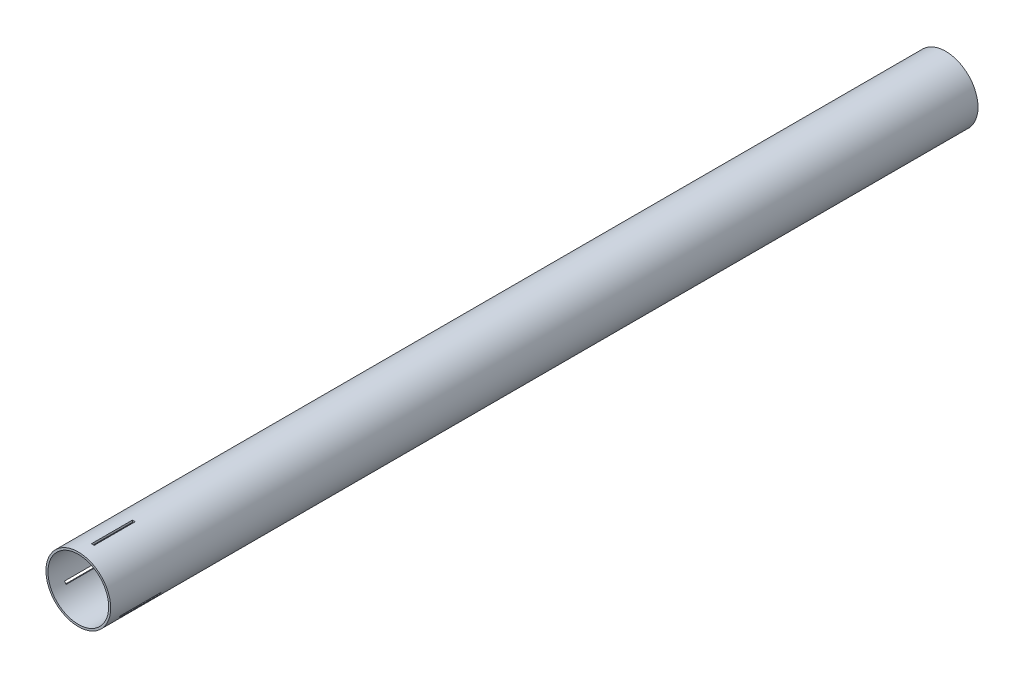
from build123d import *

# Parameters (mm, degrees)
SKETCH1_R           = 23.6982
SKETCH1_R_2         = 22.225
BOSS_EXTRUDE1_DEPTH = 635
CUT_EXTRUDE1_START  = -77.831769
SKETCH2_W           = 2
SKETCH2_H           = 30
CUT_EXTRUDE1_DEPTH  = 1.529969
CIRPATTERN2_COUNT   = 3


with BuildPart() as part:
    # Sketch1 → Boss-Extrude1 (new body)
    with BuildSketch(Plane.XY):
        Circle(SKETCH1_R)
        Circle(SKETCH1_R_2, mode=Mode.SUBTRACT)
    extrude(amount=BOSS_EXTRUDE1_DEPTH)

    # Sketch2 → Cut-Extrude1 (cut)
    with BuildSketch(Plane(origin=(0, 100, 0), x_dir=(1, 0, 0), z_dir=(0, 1, 0)).offset(CUT_EXTRUDE1_START)):
        with Locations((0.5875, -610)):
            Rectangle(SKETCH2_W, SKETCH2_H)
    cut_extrude1 = extrude(amount=CUT_EXTRUDE1_DEPTH, mode=Mode.SUBTRACT)

    # CirPattern2: Cut-Extrude1 ×3 about axis
    cirpattern2_axis = Axis((0, 0, 0), (0, 0, 1))
    for i in range(1, CIRPATTERN2_COUNT):
        add(cut_extrude1.rotate(cirpattern2_axis, i * 360 / CIRPATTERN2_COUNT), mode=Mode.SUBTRACT)


solid = part.part
